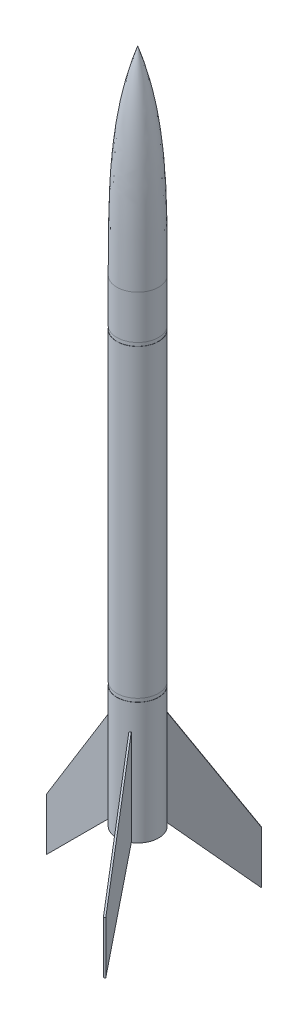
from build123d import *

# Parameters (mm, degrees)
BOSS_EXTRUDE1_DEPTH = 0.5
CIRPATTERN10_COUNT  = 3
SKETCH4_W           = 0.1
SKETCH4_H           = 2


with BuildPart() as part:
    # Sketch1 → Revolve1 (revolve)
    with BuildSketch(Plane.XY):
        with BuildLine():
            Line((0, 0), (0, 388))
            add(Edge.make_bspline(
                [(0, 388), (12, 353.463683825), (12, 313.539168354), (12, 274.912097708), (12, 274)],
                knots=[0, 0, 0, 0, 0.976387086, 1, 1, 1, 1], degree=3))
            Line((12, 274), (12, 0))
            Line((12, 0), (0, 0))
        make_face()
    revolve(axis=Axis((0, 0, 0), (0, 1, 0)))

    # Sketch2 → Boss-Extrude1 (add, symmetric)
    with BuildSketch(Plane.XY):
        Polygon((-12, 0), (-52, -40), (-52, -10), (-12, 55), (-9, 55), (-9, 0), align=None)
    boss_extrude1 = extrude(amount=BOSS_EXTRUDE1_DEPTH, both=True)

    # CirPattern10: Boss-Extrude1 ×3 about axis
    cirpattern10_axis = Axis((0, 0, 0), (0, 1, 0))
    for i in range(1, CIRPATTERN10_COUNT):
        add(boss_extrude1.rotate(cirpattern10_axis, i * 360 / CIRPATTERN10_COUNT))

    # Sketch4 → Cut-Revolve1 (revolve, cut)
    with BuildSketch(Plane.XY):
        with Locations((11.95, 71)):
            Rectangle(SKETCH4_W, SKETCH4_H)
        with Locations((11.95, 248)):
            Rectangle(SKETCH4_W, SKETCH4_H)
    revolve(axis=Axis((0, 0, 0), (0, -1, 0)), mode=Mode.SUBTRACT)


solid = part.part
